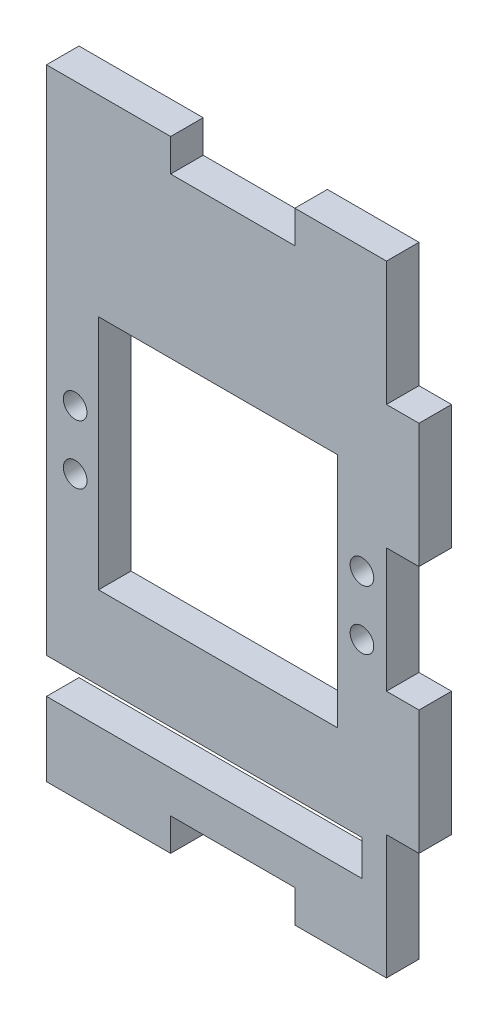
from build123d import *

# Parameters (mm, degrees)
CROQUIS2_R              = 2
CROQUIS2_W              = 40.4
CROQUIS2_H              = 40
SALIENTE_EXTRUIR1_DEPTH = 5.5
CROQUIS3_W              = 5.5
CROQUIS3_H              = 21
SALIENTE_EXTRUIR2_DEPTH = 2.5
CROQUIS4_W              = 15.5
CROQUIS4_H              = 5.5
CROQUIS4_W_2            = 21
SALIENTE_EXTRUIR3_DEPTH = 2.5
CROQUIS5_W              = 15.5
CROQUIS5_H              = 5.5
CROQUIS5_W_2            = 21
SALIENTE_EXTRUIR4_DEPTH = 2.5


with BuildPart() as part:
    # Croquis2 → Saliente-Extruir1 (new body)
    with BuildSketch(Plane.XY):
        Polygon((-10.5, 50), (-10.5, -34), (42.85, -34), (42.85, -40), (-10.5, -40), (-10.5, -50), (10.5, -50), (10.5, -47), (31.5, -47), (31.5, -50), (47, -50), (47, -31.5), (50, -31.5), (50, -10.5), (47, -10.5), (47, 10.5), (50, 10.5), (50, 31.5), (47, 31.5), (47, 50), (31.5, 50), (31.5, 47), (10.5, 47), (10.5, 50), align=None)
        with Locations((42.85, 5)):
            Circle(CROQUIS2_R, mode=Mode.SUBTRACT)
        with Locations((-5.65, 5)):
            Circle(CROQUIS2_R, mode=Mode.SUBTRACT)
        with Locations((42.85, -5)):
            Circle(CROQUIS2_R, mode=Mode.SUBTRACT)
        with Locations((-5.65, -5)):
            Circle(CROQUIS2_R, mode=Mode.SUBTRACT)
        with Locations((18.5, 0)):
            Rectangle(CROQUIS2_W, CROQUIS2_H, mode=Mode.SUBTRACT)
    extrude(amount=SALIENTE_EXTRUIR1_DEPTH)

    # Croquis3 → Saliente-Extruir2 (add)
    with BuildSketch(Plane(origin=(50, 0, 0), x_dir=(0, 0, -1), z_dir=(1, 0, 0))):
        with Locations((-2.75, -21)):
            Rectangle(CROQUIS3_W, CROQUIS3_H)
        with Locations((-2.75, 21)):
            Rectangle(CROQUIS3_W, CROQUIS3_H)
    extrude(amount=SALIENTE_EXTRUIR2_DEPTH)

    # Croquis4 → Saliente-Extruir3 (add)
    with BuildSketch(Plane(origin=(0, 50, 0), x_dir=(1, 0, 0), z_dir=(0, 1, 0))):
        with Locations((39.25, -2.75)):
            Rectangle(CROQUIS4_W, CROQUIS4_H)
        with Locations((0, -2.75)):
            Rectangle(CROQUIS4_W_2, CROQUIS4_H)
    extrude(amount=SALIENTE_EXTRUIR3_DEPTH)

    # Croquis5 → Saliente-Extruir4 (add)
    with BuildSketch(Plane.XZ.offset(50)):
        with Locations((39.25, 2.75)):
            Rectangle(CROQUIS5_W, CROQUIS5_H)
        with Locations((0, 2.75)):
            Rectangle(CROQUIS5_W_2, CROQUIS5_H)
    extrude(amount=SALIENTE_EXTRUIR4_DEPTH)


solid = part.part
